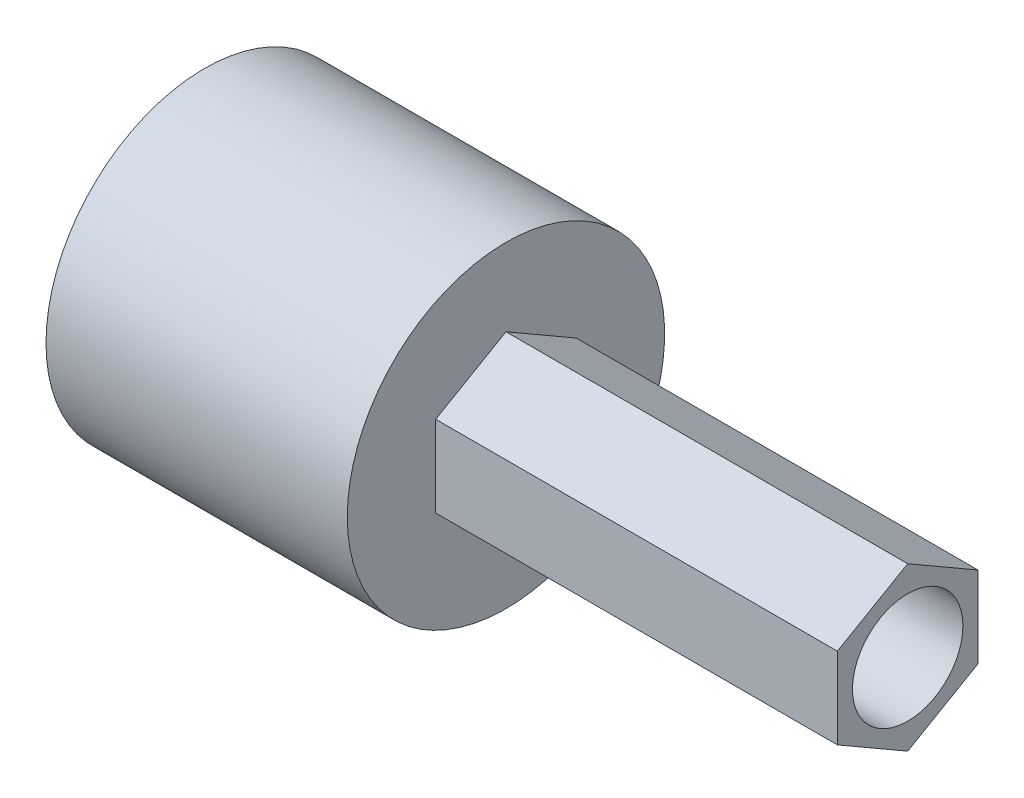
from build123d import *

# Parameters (mm, degrees)
SALIENTE_EXTRUIR1_DEPTH = 20
CROQUIS2_R              = 7.9
CROQUIS2_R_2            = 4.9
SALIENTE_EXTRUIR2_DEPTH = 3
SALIENTE_EXTRUIR3_START = 3
CROQUIS2_3_R            = 7.9
CROQUIS2_3_R_2          = 4.9
SALIENTE_EXTRUIR3_DEPTH = 12
CROQUIS3_R              = 2.75
CORTAR_EXTRUIR1_DEPTH   = 37.73989657
CROQUIS5_R              = 2.75
SALIENTE_EXTRUIR4_DEPTH = 0.3


with BuildPart() as part:
    # Croquis1 → Saliente-Extruir1 (new body)
    with BuildSketch(Plane(origin=(0, 0, 0), x_dir=(0, 0, -1), z_dir=(1, 0, 0))):
        Polygon((-3.5, -2.020725942), (0, -4.041451884), (3.5, -2.020725942), (3.5, 2.020725942), (0, 4.041451884), (-3.5, 2.020725942), align=None)
    extrude(amount=SALIENTE_EXTRUIR1_DEPTH)

    # Croquis2 → Saliente-Extruir2 (add)
    with BuildSketch(Plane.ZY):
        Circle(CROQUIS2_R)
        Circle(CROQUIS2_R_2, mode=Mode.SUBTRACT)
        Circle(CROQUIS2_R_2)
        Polygon((3.5, -2.020725942), (3.5, 2.020725942), (0, 4.041451884), (-3.5, 2.020725942), (-3.5, -2.020725942), (0, -4.041451884), align=None, mode=Mode.SUBTRACT)
        Polygon((0, -4.041451884), (3.5, -2.020725942), (3.5, 2.020725942), (0, 4.041451884), (-3.5, 2.020725942), (-3.5, -2.020725942), align=None)
    extrude(amount=SALIENTE_EXTRUIR2_DEPTH)

    # Croquis2_3 → Saliente-Extruir3 (add)
    with BuildSketch(Plane.ZY.offset(SALIENTE_EXTRUIR3_START)):
        Circle(CROQUIS2_3_R)
        Circle(CROQUIS2_3_R_2, mode=Mode.SUBTRACT)
    extrude(amount=SALIENTE_EXTRUIR3_DEPTH)

    # Croquis3 → Cortar-Extruir1 (cut, through all)
    with BuildSketch(Plane(origin=(20, 0, 0), x_dir=(0, 0, -1), z_dir=(1, 0, 0))):
        Circle(CROQUIS3_R)
    extrude(amount=-CORTAR_EXTRUIR1_DEPTH, mode=Mode.SUBTRACT)

    # Croquis5 → Saliente-Extruir4 (add)
    with BuildSketch(Plane.ZY.offset(3)):
        with Locations(Location((0, 0, 0), (0, 0, 180))):
            Circle(CROQUIS5_R)
    extrude(amount=-SALIENTE_EXTRUIR4_DEPTH)


solid = part.part
